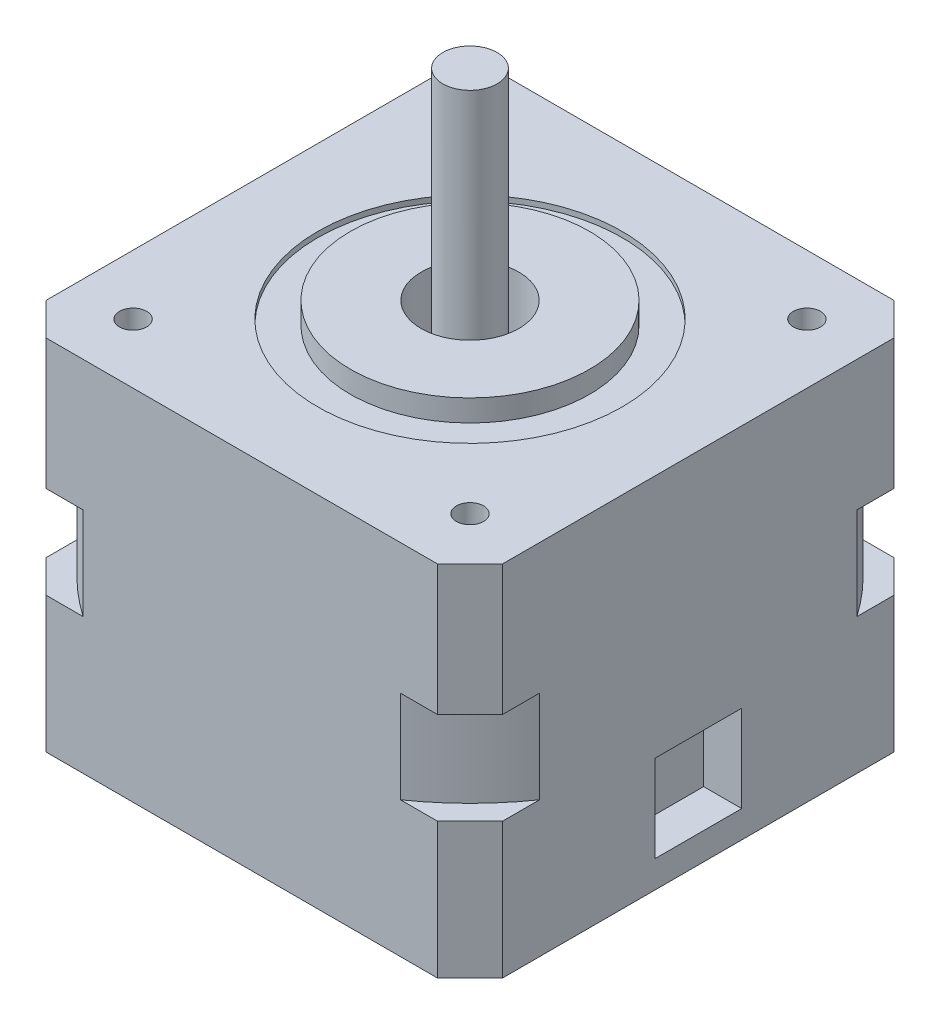
from build123d import *

# Parameters (mm, degrees)
BOSS_EXTRUDE1_DEPTH = 33
SKETCH3_W           = 4.5
SKETCH3_H           = 4.99999
SKETCH3_W_2         = 3
SKETCH3_H_2         = 0.5
SKETCH4_R           = 1.25
CUT_EXTRUDE1_DEPTH  = 45.395945761
SKETCH5_R           = 3.25
SKETCH5_R_2         = 4.75
CUT_EXTRUDE2_DEPTH  = 3.5
SKETCH6_W           = 8
SKETCH6_H           = 8
CUT_EXTRUDE3_DEPTH  = 3.5
SKETCH7_W           = 6.5
SKETCH7_H           = 1.5
SKETCH7_W_2         = 2.5
SKETCH7_H_2         = 25
SKETCH8_R           = 2.742
SKETCH8_R_2         = 1.25
BOSS_EXTRUDE2_DEPTH = 2.992
SKETCH8_3_R         = 1.25
BOSS_EXTRUDE3_DEPTH = 21.336
CUT_EXTRUDE4_DEPTH  = 1.016


with BuildPart() as part:
    # Sketch1 → Boss-Extrude1 (new body)
    with BuildSketch(Plane(origin=(0, 0, 0), x_dir=(1, 0, 0), z_dir=(0, 1, 0))):
        Polygon((-18, 21), (-21, 18), (-21, -18), (-18, -21), (18, -21), (21, -18), (21, 18), (18, 21), align=None)
    extrude(amount=BOSS_EXTRUDE1_DEPTH)

    # Sketch3 → Cut-Revolve2 (revolve, cut)
    with BuildSketch(Plane(origin=(0, 0, 0), x_dir=(0.7071067811865481, 0, -0.7071067811865469), z_dir=(0.7071067811865469, 0, 0.7071067811865481)), mode=Mode.PRIVATE) as cut_revolve2_sk:
        with Locations((2.25, 30.500005)):
            Rectangle(SKETCH3_W, SKETCH3_H)
        Polygon((29.355164466, 12.5), (27.577164466, 12.5), (25.577164466, 12.5), (25.577164466, 21), (27.577164466, 21), (29.355164466, 21), align=None)
        with Locations((12.5, 32.75)):
            Rectangle(SKETCH3_W_2, SKETCH3_H_2)
    revolve(cut_revolve2_sk.sketch.rotate(Axis((0, 33, 0), (0, -1, 0)), 225), axis=Axis((0, 33, 0), (0, -1, 0)), mode=Mode.SUBTRACT)

    # Sketch4 → Cut-Extrude1 (cut, through all)
    with BuildSketch(Plane(origin=(0, 33, 0), x_dir=(1, 0, 0), z_dir=(0, 1, 0))):
        with Locations(Location((-15.5, 15.5, 0), (0, 0, 270))):
            Circle(SKETCH4_R)
        with Locations(Location((15.5, 15.5, 0), (0, 0, 270))):
            Circle(SKETCH4_R)
        with Locations(Location((15.5, -15.5, 0), (0, 0, 270))):
            Circle(SKETCH4_R)
        with Locations(Location((-15.5, -15.5, 0), (0, 0, 270))):
            Circle(SKETCH4_R)
    extrude(amount=-CUT_EXTRUDE1_DEPTH, mode=Mode.SUBTRACT)

    # Sketch5 → Cut-Extrude2 (cut)
    with BuildSketch(Plane.XZ):
        with Locations(Location((-15.5, 15.5, 0), (0, 0, 270))):
            Circle(SKETCH5_R)
        with Locations(Location((-15.5, -15.5, 0), (0, 0, 270))):
            Circle(SKETCH5_R)
        with Locations(Location((15.5, -15.5, 0), (0, 0, 270))):
            Circle(SKETCH5_R)
        with Locations(Location((15.5, 15.5, 0), (0, 0, 270))):
            Circle(SKETCH5_R)
        with Locations(Location((0, 0, 0), (0, 0, 270))):
            Circle(SKETCH5_R_2)
    extrude(amount=-CUT_EXTRUDE2_DEPTH, mode=Mode.SUBTRACT)

    # Sketch6 → Cut-Extrude3 (cut)
    with BuildSketch(Plane(origin=(21, 0, 0), x_dir=(0, 0, -1), z_dir=(1, 0, 0))):
        with Locations((0, 6.5)):
            Rectangle(SKETCH6_W, SKETCH6_H)
    extrude(amount=-CUT_EXTRUDE3_DEPTH, mode=Mode.SUBTRACT)

    # Sketch7 → Revolve1 (revolve)
    with BuildSketch(Plane(origin=(0, 0, 0), x_dir=(0.7071067811865481, 0, -0.7071067811865469), z_dir=(0.7071067811865469, 0, 0.7071067811865481)), mode=Mode.PRIVATE) as revolve1_sk:
        with Locations((7.75, 33.75)):
            Rectangle(SKETCH7_W, SKETCH7_H)
        with Locations((1.25, 40.50001)):
            Rectangle(SKETCH7_W_2, SKETCH7_H_2)
    revolve(revolve1_sk.sketch.rotate(Axis((0, 33, 0), (0, -1, 0)), 225), axis=Axis((0, 33, 0), (0, -1, 0)))



with BuildPart() as body_2:
    # Sketch8 → Boss-Extrude2 (new body)
    with BuildSketch(Plane.XZ):
        with Locations(Location((-15.5, 15.5, 0), (0, 0, 270))):
            Circle(SKETCH8_R)
        with Locations(Location((-15.5, 15.5, 0), (0, 0, 90))):
            Circle(SKETCH8_R_2, mode=Mode.SUBTRACT)
        with Locations(Location((-15.5, 15.5, 0), (0, 0, 90))):
            Circle(SKETCH8_R_2)
        with Locations(Location((15.5, 15.5, 0), (0, 0, 270))):
            Circle(SKETCH8_R)
        with Locations(Location((15.5, 15.5, 0), (0, 0, 90))):
            Circle(SKETCH8_R_2, mode=Mode.SUBTRACT)
        with Locations(Location((15.5, 15.5, 0), (0, 0, 90))):
            Circle(SKETCH8_R_2)
        with Locations(Location((15.5, -15.5, 0), (0, 0, 270))):
            Circle(SKETCH8_R)
        with Locations(Location((15.5, -15.5, 0), (0, 0, 90))):
            Circle(SKETCH8_R_2, mode=Mode.SUBTRACT)
        with Locations(Location((15.5, -15.5, 0), (0, 0, 90))):
            Circle(SKETCH8_R_2)
        with Locations(Location((-15.5, -15.5, 0), (0, 0, 270))):
            Circle(SKETCH8_R)
        with Locations(Location((-15.5, -15.5, 0), (0, 0, 90))):
            Circle(SKETCH8_R_2, mode=Mode.SUBTRACT)
        with Locations(Location((-15.5, -15.5, 0), (0, 0, 90))):
            Circle(SKETCH8_R_2)
    extrude(amount=-BOSS_EXTRUDE2_DEPTH)


with BuildPart() as part_1:
    add(part.part)

    add(body_2.part)  # Boss-Extrude3 merges body 2
    # Sketch8_3 → Boss-Extrude3 (add)
    with BuildSketch(Plane.XZ):
        with Locations(Location((-15.5, 15.5, 0), (0, 0, 270))):
            Circle(SKETCH8_3_R)
        with Locations(Location((-15.5, -15.5, 0), (0, 0, 270))):
            Circle(SKETCH8_3_R)
        with Locations(Location((15.5, -15.5, 0), (0, 0, 270))):
            Circle(SKETCH8_3_R)
        with Locations(Location((15.5, 15.5, 0), (0, 0, 270))):
            Circle(SKETCH8_3_R)
    extrude(amount=-BOSS_EXTRUDE3_DEPTH)

    # Sketch9 → Cut-Extrude4 (cut)
    with BuildSketch(Plane.XZ):
        with BuildLine():
            Line((16.262, -16.262), (18.133993166, -16.262))
            ThreePointArc((18.133993166, -16.262), (18.214864017, -15.884808224), (18.242, -15.5))
            ThreePointArc((18.242, -15.5), (18.214864017, -15.115191776), (18.133993166, -14.738))
            Line((18.133993166, -14.738), (16.262, -14.738))
            Line((16.262, -14.738), (16.262, -12.866006834))
            ThreePointArc((16.262, -12.866006834), (15.5, -12.758), (14.738, -12.866006834))
            Line((14.738, -12.866006834), (14.738, -14.738))
            Line((14.738, -14.738), (12.866006834, -14.738))
            ThreePointArc((12.866006834, -14.738), (12.758, -15.5), (12.866006834, -16.262))
            Line((12.866006834, -16.262), (14.738, -16.262))
            Line((14.738, -16.262), (14.738, -18.133993166))
            ThreePointArc((14.738, -18.133993166), (15.5, -18.242), (16.262, -18.133993166))
            Line((16.262, -18.133993166), (16.262, -16.262))
        make_face()
        with BuildLine():
            ThreePointArc((-12.758, -15.5), (-12.785135983, -15.115191776), (-12.866006834, -14.738))
            Line((-12.866006834, -14.738), (-14.738, -14.738))
            Line((-14.738, -14.738), (-14.738, -12.866006834))
            ThreePointArc((-14.738, -12.866006834), (-15.5, -12.758), (-16.262, -12.866006834))
            Line((-16.262, -12.866006834), (-16.262, -14.738))
            Line((-16.262, -14.738), (-18.133993166, -14.738))
            ThreePointArc((-18.133993166, -14.738), (-18.242, -15.5), (-18.133993166, -16.262))
            Line((-18.133993166, -16.262), (-16.262, -16.262))
            Line((-16.262, -16.262), (-16.262, -18.133993166))
            ThreePointArc((-16.262, -18.133993166), (-15.5, -18.242), (-14.738, -18.133993166))
            Line((-14.738, -18.133993166), (-14.738, -16.262))
            Line((-14.738, -16.262), (-12.866006834, -16.262))
            ThreePointArc((-12.866006834, -16.262), (-12.785135983, -15.884808224), (-12.758, -15.5))
        make_face()
        with BuildLine():
            Line((-16.262, 16.262), (-18.133993166, 16.262))
            ThreePointArc((-18.133993166, 16.262), (-18.242, 15.5), (-18.133993166, 14.738))
            Line((-18.133993166, 14.738), (-16.262, 14.738))
            Line((-16.262, 14.738), (-16.262, 12.866006834))
            ThreePointArc((-16.262, 12.866006834), (-15.5, 12.758), (-14.738, 12.866006834))
            Line((-14.738, 12.866006834), (-14.738, 14.738))
            Line((-14.738, 14.738), (-12.866006834, 14.738))
            ThreePointArc((-12.866006834, 14.738), (-12.785135983, 15.115191776), (-12.758, 15.5))
            ThreePointArc((-12.758, 15.5), (-12.785135983, 15.884808224), (-12.866006834, 16.262))
            Line((-12.866006834, 16.262), (-14.738, 16.262))
            Line((-14.738, 16.262), (-14.738, 18.133993166))
            ThreePointArc((-14.738, 18.133993166), (-15.5, 18.242), (-16.262, 18.133993166))
            Line((-16.262, 18.133993166), (-16.262, 16.262))
        make_face()
        with BuildLine():
            ThreePointArc((12.866006834, 16.262), (12.758, 15.5), (12.866006834, 14.738))
            Line((12.866006834, 14.738), (14.738, 14.738))
            Line((14.738, 14.738), (14.738, 12.866006834))
            ThreePointArc((14.738, 12.866006834), (15.5, 12.758), (16.262, 12.866006834))
            Line((16.262, 12.866006834), (16.262, 14.738))
            Line((16.262, 14.738), (18.133993166, 14.738))
            ThreePointArc((18.133993166, 14.738), (18.214864017, 15.115191776), (18.242, 15.5))
            ThreePointArc((18.242, 15.5), (18.214864017, 15.884808224), (18.133993166, 16.262))
            Line((18.133993166, 16.262), (16.262, 16.262))
            Line((16.262, 16.262), (16.262, 18.133993166))
            ThreePointArc((16.262, 18.133993166), (15.5, 18.242), (14.738, 18.133993166))
            Line((14.738, 18.133993166), (14.738, 16.262))
            Line((14.738, 16.262), (12.866006834, 16.262))
        make_face()
    extrude(amount=-CUT_EXTRUDE4_DEPTH, mode=Mode.SUBTRACT)


solid = part_1.part
